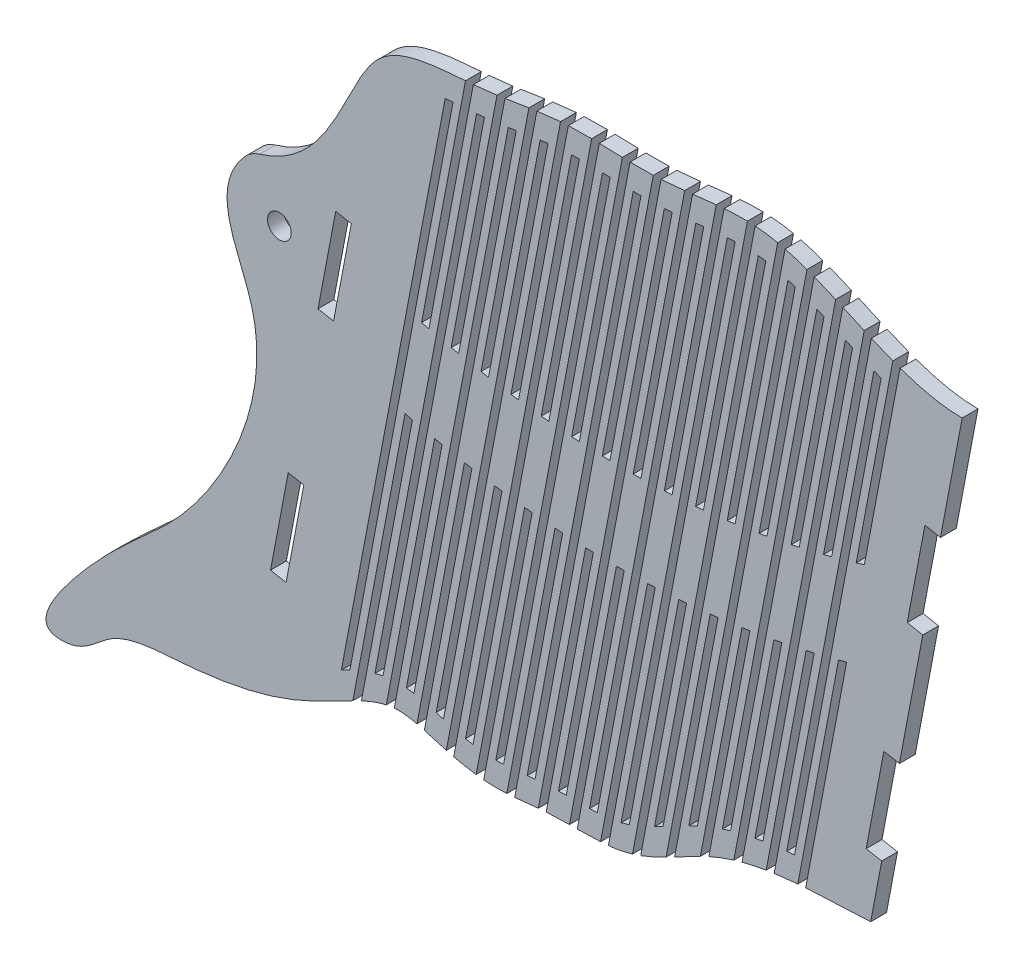
from build123d import *

# Parameters (mm, degrees)
SKETCH1_R           = 2.38125
BOSS_EXTRUDE1_DEPTH = 3.175
CUT_EXTRUDE1_DEPTH  = 3.175
CUT_EXTRUDE2_DEPTH  = 5.08


with BuildPart() as part:
    # Sketch1 → Boss-Extrude1 (new body)
    with BuildSketch(Plane.XY):
        with BuildLine():
            add(Edge.make_bspline(
                [(262.965914683, 222.176563319), (252.776182879, 221.634979572), (234.614709745, 222.046492101), (215.715433641, 207.839747079), (199.776901525, 209.397609599), (187.370815085, 207.163447991), (177.227729499, 209.313258014), (167.480873749, 212.716340292), (157.834954982, 208.138608283), (144.68413983, 200.908281223), (128.175962311, 197.807744291), (111.188740979, 197.561370772), (105.088410147, 189.875870369), (93.870335672, 189.645044346), (109.304742609, 211.179651417), (127.811684606, 222.332999181), (145.741997275, 257.387754377), (132.813268714, 279.641803985), (133.809830146, 288.366944204), (137.393134843, 292.39498657)],
                knots=[0, 0, 0, 0, 0.108342834, 0.179804744, 0.231480998, 0.269558306, 0.310047914, 0.3388763, 0.372965647, 0.414981364, 0.49670609, 0.548446486, 0.578686653, 0.5942621, 0.641812672, 0.740934207, 0.901270829, 0.951710023, 0.994791035, 0.994791035, 0.994791035, 0.994791035], degree=3))
            Line((262.965914683, 222.176563319), (265.179854829, 233.84009186))
            Line((265.179854829, 233.84009186), (262.060552767, 234.432189529))
            Line((262.060552767, 234.432189529), (265.61313878, 253.148001898))
            Line((265.61313878, 253.148001898), (268.732440842, 252.555904229))
            Line((268.732440842, 252.555904229), (273.419011411, 277.245799168))
            Line((273.419011411, 277.245799168), (270.299709349, 277.837896837))
            Line((270.299709349, 277.837896837), (273.852295362, 296.553709205))
            Line((273.852295362, 296.553709205), (276.971597424, 295.961611536))
            Line((276.971597424, 295.961611536), (281.327401418, 318.908954674))
            add(Edge.make_bspline(
                [(140.318014573, 294.258156132), (144.61023342, 295.541868895), (152.097280003, 300.900381836), (157.875345692, 312.565873253), (165.48589024, 327.616550709), (184.032411792, 327.009565774), (201.917650096, 331.22328454), (220.739688935, 328.976192412), (248.527948343, 335.404657274), (266.945821835, 318.91013876), (281.327401418, 318.908954674)],
                knots=[0.008505479, 0.008505479, 0.008505479, 0.008505479, 0.084335044, 0.182888737, 0.251299887, 0.38213826, 0.483340136, 0.605314817, 0.732969852, 1, 1, 1, 1], degree=3))
            ThreePointArc((140.318014573, 294.258156132), (138.725920408, 293.53010797), (137.393134843, 292.39498657))
        make_face()
        with Locations((144.299338724, 283.736845769)):
            Circle(SKETCH1_R, mode=Mode.SUBTRACT)
    extrude(amount=BOSS_EXTRUDE1_DEPTH)

    # Sketch2 → Cut-Extrude1 (cut)
    with BuildSketch(Plane.XY.offset(3.175)):
        with BuildLine():
            add(Edge.make_bspline(
                [(253.499129309, 281.265187804), (254.043605807, 281.405759721), (254.587907948, 281.549220511), (255.132035737, 281.695570177)],
                knots=[0.668787999, 0.668787999, 0.668787999, 0.668787999, 0.68090048, 0.68090048, 0.68090048, 0.68090048], degree=3))
            Line((255.132035737, 281.695570177), (265.175333522, 334.605894149))
            Line((265.175333522, 334.605894149), (263.624121137, 334.605894149))
            Line((263.624121137, 334.605894149), (253.499129309, 281.265187804))
        make_face()
        with BuildLine():
            Line((245.215002967, 204.934043958), (246.761298802, 204.908142481))
            Line((246.761298802, 204.908142481), (258.146846352, 264.889736415))
            add(Edge.make_bspline(
                [(256.510850204, 264.443076714), (257.056244674, 264.589276612), (257.601576721, 264.738163179), (258.146846352, 264.889736415)],
                knots=[0.805120326, 0.805120326, 0.805120326, 0.805120326, 0.818669259, 0.818669259, 0.818669259, 0.818669259], degree=3))
            Line((256.510850204, 264.443076714), (245.215002967, 204.934043958))
        make_face()
        with BuildLine():
            add(Edge.make_bspline(
                [(247.690951874, 226.150024326), (247.165611556, 226.104180829), (246.638974138, 226.054367703), (246.111253526, 225.999953943)],
                knots=[0.092913574, 0.092913574, 0.092913574, 0.092913574, 0.102289269, 0.102289269, 0.102289269, 0.102289269], degree=3))
            Line((247.690951874, 226.150024326), (265.064099585, 317.675626133))
            add(Edge.make_bspline(
                [(263.622438548, 318.252766971), (264.099576579, 318.057329111), (264.580064116, 317.864646955), (265.064099585, 317.675626133)],
                knots=[0.896580018, 0.896580018, 0.896580018, 0.896580018, 0.905747211, 0.905747211, 0.905747211, 0.905747211], degree=3))
            Line((263.622438548, 318.252766971), (246.111253526, 225.999953943))
        make_face()
        with BuildLine():
            Line((239.029819629, 205.037649869), (240.576115463, 205.011748391))
            Line((240.576115463, 205.011748391), (251.622197629, 263.204963265))
            add(Edge.make_bspline(
                [(249.999021721, 262.825843438), (250.540141691, 262.949576802), (251.081200325, 263.075950079), (251.622197629, 263.204963265)],
                knots=[0.751221614, 0.751221614, 0.751221614, 0.751221614, 0.764652129, 0.764652129, 0.764652129, 0.764652129], degree=3))
            Line((249.999021721, 262.825843438), (239.029819629, 205.037649869))
        make_face()
        with BuildLine():
            add(Edge.make_bspline(
                [(241.337825106, 225.36886694), (240.803093478, 225.280719583), (240.267885039, 225.185949449), (239.73251013, 225.083842468)],
                knots=[0.130418732, 0.130418732, 0.130418732, 0.130418732, 0.139836165, 0.139836165, 0.139836165, 0.139836165], degree=3))
            Line((241.337825106, 225.36886694), (259.320014432, 320.103035281))
            add(Edge.make_bspline(
                [(257.890031503, 320.741698985), (258.363755003, 320.529426446), (258.840381441, 320.316231273), (259.320014432, 320.103035281)],
                knots=[0.858867817, 0.858867817, 0.858867817, 0.858867817, 0.868457537, 0.868457537, 0.868457537, 0.868457537], degree=3))
            Line((257.890031503, 320.741698985), (239.73251013, 225.083842468))
        make_face()
        with BuildLine():
            Line((232.84463629, 205.141255779), (234.390932125, 205.115354302))
            Line((234.390932125, 205.115354302), (245.148329805, 261.787715172))
            add(Edge.make_bspline(
                [(243.537643759, 261.474394711), (244.074599393, 261.576240113), (244.61149474, 261.680680265), (245.148329805, 261.787715172)],
                knots=[0.697788906, 0.697788906, 0.697788906, 0.697788906, 0.711104053, 0.711104053, 0.711104053, 0.711104053], degree=3))
            Line((243.537643759, 261.474394711), (232.84463629, 205.141255779))
        make_face()
        with BuildLine():
            add(Edge.make_bspline(
                [(234.860021519, 223.930884371), (234.310062445, 223.772921472), (233.760927699, 223.604859066), (233.212957192, 223.425915044)],
                knots=[0.168429697, 0.168429697, 0.168429697, 0.168429697, 0.178137216, 0.178137216, 0.178137216, 0.178137216], degree=3))
            Line((234.860021519, 223.930884371), (253.598134874, 322.647428436))
            add(Edge.make_bspline(
                [(252.163030291, 323.259110131), (252.638612159, 323.0601036), (253.116939993, 322.855850634), (253.598134874, 322.647428436)],
                knots=[0.819270674, 0.819270674, 0.819270674, 0.819270674, 0.829371507, 0.829371507, 0.829371507, 0.829371507], degree=3))
            Line((252.163030291, 323.259110131), (233.212957192, 223.425915044))
        make_face()
        with BuildLine():
            Line((226.659452952, 205.24486169), (228.205748786, 205.218960212))
            Line((228.205748786, 205.218960212), (238.723942554, 260.631141732))
            add(Edge.make_bspline(
                [(237.125429941, 260.381953617), (237.65832675, 260.462465209), (238.191164286, 260.545527914), (238.723942554, 260.631141732)],
                knots=[0.644810319, 0.644810319, 0.644810319, 0.644810319, 0.658013022, 0.658013022, 0.658013022, 0.658013022], degree=3))
            Line((237.125429941, 260.381953617), (226.659452952, 205.24486169))
        make_face()
        with BuildLine():
            add(Edge.make_bspline(
                [(228.182680044, 221.44169188), (227.62915356, 221.18605526), (227.085464807, 220.9242222), (226.525650291, 220.646903869), (226.500774627, 220.634565098), (226.475917658, 220.622219916)],
                knots=[0.208362401, 0.208362401, 0.208362401, 0.208362401, 0.21875, 0.21875, 0.219233424, 0.219233424, 0.219233424, 0.219233424], degree=3))
            Line((228.182680044, 221.44169188), (247.826108711, 324.927638132))
            add(Edge.make_bspline(
                [(246.365298916, 325.403899059), (246.546035345, 325.348303874), (246.727206568, 325.29128004), (247.21336108, 325.134927326), (247.519123138, 325.033093448), (247.826108711, 324.927638132)],
                knots=[0.777218205, 0.777218205, 0.777218205, 0.777218205, 0.78125, 0.78125, 0.788010833, 0.788010833, 0.788010833, 0.788010833], degree=3))
            Line((246.365298916, 325.403899059), (226.475917658, 220.622219916))
        make_face()
        with BuildLine():
            Line((220.474269613, 205.3484676), (222.020565448, 205.322566123))
            Line((222.020565448, 205.322566123), (232.347790116, 259.728679999))
            add(Edge.make_bspline(
                [(230.761147646, 259.542026439), (231.290086761, 259.601735375), (231.818967582, 259.663953228), (232.347790116, 259.728679999)],
                knots=[0.592274468, 0.592274468, 0.592274468, 0.592274468, 0.605367529, 0.605367529, 0.605367529, 0.605367529], degree=3))
            Line((230.761147646, 259.542026439), (220.474269613, 205.3484676))
        make_face()
        with BuildLine():
            add(Edge.make_bspline(
                [(221.31044637, 217.925763985), (220.728454403, 217.619691582), (220.155323639, 217.322096361), (219.590497955, 217.036825093)],
                knots=[0.254448206, 0.254448206, 0.254448206, 0.254448206, 0.2669221, 0.2669221, 0.2669221, 0.2669221], degree=3))
            Line((221.31044637, 217.925763985), (241.914774696, 326.473943123))
            add(Edge.make_bspline(
                [(240.402355557, 326.678314558), (240.51553003, 326.666479541), (240.628655957, 326.653854383), (241.131333589, 326.594229306), (241.522161775, 326.538606176), (241.914774696, 326.473943123)],
                knots=[0.731724904, 0.731724904, 0.731724904, 0.731724904, 0.734375, 0.734375, 0.743474077, 0.743474077, 0.743474077, 0.743474077], degree=3))
            Line((240.402355557, 326.678314558), (219.590497955, 217.036825093))
        make_face()
        with BuildLine():
            Line((214.289086275, 205.452073511), (215.835382109, 205.426172033))
            Line((215.835382109, 205.426172033), (226.018678141, 259.074037877))
            add(Edge.make_bspline(
                [(224.443614913, 258.948386336), (224.968693332, 258.987802088), (225.493714406, 259.029685935), (226.018678141, 259.074037877)],
                knots=[0.540170436, 0.540170436, 0.540170436, 0.540170436, 0.553156541, 0.553156541, 0.553156541, 0.553156541], degree=3))
            Line((224.443614913, 258.948386336), (214.289086275, 205.452073511))
        make_face()
        with BuildLine():
            add(Edge.make_bspline(
                [(214.517894834, 214.829619296), (214.247034512, 214.737836871), (213.978102393, 214.652055286), (213.430222607, 214.489129562), (213.151410621, 214.41255175), (212.87434127, 214.343145452)],
                knots=[0.305963237, 0.305963237, 0.305963237, 0.305963237, 0.3125, 0.3125, 0.319373089, 0.319373089, 0.319373089, 0.319373089], degree=3))
            Line((214.517894834, 214.829619296), (235.769524156, 326.787923887))
            add(Edge.make_bspline(
                [(234.201393662, 326.698795529), (234.255346074, 326.702633485), (234.309221369, 326.706393879), (234.838026355, 326.742575126), (235.306922462, 326.768863442), (235.769524156, 326.787923887)],
                knots=[0.68638957, 0.68638957, 0.68638957, 0.68638957, 0.6875, 0.6875, 0.697304527, 0.697304527, 0.697304527, 0.697304527], degree=3))
            Line((234.201393662, 326.698795529), (212.87434127, 214.343145452))
        make_face()
        with BuildLine():
            Line((208.103902936, 205.555679421), (209.650198771, 205.529777944))
            Line((209.650198771, 205.529777944), (219.735460771, 258.66117873))
            add(Edge.make_bspline(
                [(218.171697576, 258.595058271), (218.693008399, 258.614669845), (219.214262795, 258.636709998), (219.735460771, 258.66117873)],
                knots=[0.488487746, 0.488487746, 0.488487746, 0.488487746, 0.501369475, 0.501369475, 0.501369475, 0.501369475], degree=3))
            Line((218.171697576, 258.595058271), (208.103902936, 205.555679421))
        make_face()
        with BuildLine():
            add(Edge.make_bspline(
                [(208.099228735, 213.703186156), (207.591075339, 213.677150944), (207.070084736, 213.658996658), (206.537198661, 213.646196164)],
                knots=[0.355873482, 0.355873482, 0.355873482, 0.355873482, 0.366464143, 0.366464143, 0.366464143, 0.366464143], degree=3))
            Line((208.099228735, 213.703186156), (229.459237081, 326.232455518))
            add(Edge.make_bspline(
                [(227.873079236, 326.048355071), (228.407151252, 326.110395372), (228.935918369, 326.172328006), (229.459237081, 326.232455518)],
                knots=[0.645046779, 0.645046779, 0.645046779, 0.645046779, 0.655063219, 0.655063219, 0.655063219, 0.655063219], degree=3))
            Line((227.873079236, 326.048355071), (206.537198661, 213.646196164))
        make_face()
        with BuildLine():
            Line((201.918719597, 205.659285332), (203.465015432, 205.633383854))
            Line((203.465015432, 205.633383854), (213.497037926, 258.484307093))
            add(Edge.make_bspline(
                [(211.944306596, 258.476304952), (212.461939242, 258.476582023), (212.979516349, 258.479249404), (213.497037926, 258.484307093)],
                knots=[0.437216339, 0.437216339, 0.437216339, 0.437216339, 0.449996168, 0.449996168, 0.449996168, 0.449996168], degree=3))
            Line((211.944306596, 258.476304952), (201.918719597, 205.659285332))
        make_face()
        with BuildLine():
            add(Edge.make_bspline(
                [(201.874915521, 213.600647189), (201.363066188, 213.594670858), (200.844012269, 213.585825202), (200.318218815, 213.571754568)],
                knots=[0.395679123, 0.395679123, 0.395679123, 0.395679123, 0.404839, 0.404839, 0.404839, 0.404839], degree=3))
            Line((201.874915521, 213.600647189), (223.124845816, 325.550000927))
            add(Edge.make_bspline(
                [(221.550966655, 325.43058731), (221.691385054, 325.439704151), (221.83151345, 325.449244992), (222.358044019, 325.486768882), (222.742590767, 325.517232456), (223.124845816, 325.550000927)],
                knots=[0.6069211, 0.6069211, 0.6069211, 0.6069211, 0.609375, 0.609375, 0.616168854, 0.616168854, 0.616168854, 0.616168854], degree=3))
            Line((221.550966655, 325.43058731), (200.318218815, 213.571754568))
        make_face()
        with BuildLine():
            Line((195.733536259, 205.762891242), (197.279832094, 205.736989765))
            Line((197.279832094, 205.736989765), (207.30235278, 258.537855371))
            add(Edge.make_bspline(
                [(205.76039559, 258.586613795), (206.274435994, 258.56800776), (206.788421723, 258.551754952), (207.30235278, 258.537855371)],
                knots=[0.38634655, 0.38634655, 0.38634655, 0.38634655, 0.39902686, 0.39902686, 0.39902686, 0.39902686], degree=3))
            Line((205.76039559, 258.586613795), (195.733536259, 205.762891242))
        make_face()
        with BuildLine():
            add(Edge.make_bspline(
                [(195.607404973, 213.270535071), (195.299596957, 213.240436159), (194.995208565, 213.209395051), (194.469358789, 213.154700208), (194.246387588, 213.131206822), (194.0253074, 213.107825036)],
                knots=[0.431979794, 0.431979794, 0.431979794, 0.431979794, 0.4375, 0.4375, 0.44162397, 0.44162397, 0.44162397, 0.44162397], degree=3))
            Line((195.607404973, 213.270535071), (216.869510709, 325.284031734))
            add(Edge.make_bspline(
                [(215.319998499, 325.292988632), (215.832966234, 325.286572831), (216.34950204, 325.283200043), (216.869510709, 325.284031734)],
                knots=[0.570205478, 0.570205478, 0.570205478, 0.570205478, 0.579503584, 0.579503584, 0.579503584, 0.579503584], degree=3))
            Line((215.319998499, 325.292988632), (194.0253074, 213.107825036))
        make_face()
        with BuildLine():
            Line((189.54835292, 205.866497153), (191.094648755, 205.840595675))
            Line((191.094648755, 205.840595675), (201.150389427, 258.816471546))
            add(Edge.make_bspline(
                [(199.618958535, 258.920684841), (200.129489337, 258.883629799), (200.639966301, 258.848892034), (201.150389427, 258.816471546)],
                knots=[0.335869086, 0.335869086, 0.335869086, 0.335869086, 0.348452167, 0.348452167, 0.348452167, 0.348452167], degree=3))
            Line((199.618958535, 258.920684841), (189.54835292, 205.866497153))
        make_face()
        with BuildLine():
            add(Edge.make_bspline(
                [(189.291976124, 212.687978697), (188.767798722, 212.66285431), (188.257803915, 212.650005382), (187.75246868, 212.652428897), (187.743251753, 212.652478424), (187.734035582, 212.652533268)],
                knots=[0.473119308, 0.473119308, 0.473119308, 0.473119308, 0.484375, 0.484375, 0.484584129, 0.484584129, 0.484584129, 0.484584129], degree=3))
            Line((189.291976124, 212.687978697), (210.687875088, 325.406327809))
            add(Edge.make_bspline(
                [(209.145203902, 325.451324741), (209.655008256, 325.437403387), (210.16927386, 325.42199771), (210.687875088, 325.406327809)],
                knots=[0.53175045, 0.53175045, 0.53175045, 0.53175045, 0.541589122, 0.541589122, 0.541589122, 0.541589122], degree=3))
            Line((209.145203902, 325.451324741), (187.734035582, 212.652533268))
        make_face()
        with BuildLine():
            Line((183.363169582, 205.970103063), (184.909465416, 205.944201586))
            Line((184.909465416, 205.944201586), (195.040170688, 259.315007622))
            add(Edge.make_bspline(
                [(193.519027608, 259.473419396), (194.026128329, 259.418333062), (194.533176022, 259.365529137), (195.040170688, 259.315007622)],
                knots=[0.285775008, 0.285775008, 0.285775008, 0.285775008, 0.298263062, 0.298263062, 0.298263062, 0.298263062], degree=3))
            Line((193.519027608, 259.473419396), (183.363169582, 205.970103063))
        make_face()
        with BuildLine():
            add(Edge.make_bspline(
                [(183.160233801, 213.073123752), (182.665527017, 213.156792009), (182.166440011, 213.251825484), (181.662968815, 213.357330632)],
                knots=[0.518388217, 0.518388217, 0.518388217, 0.518388217, 0.529054659, 0.529054659, 0.529054659, 0.529054659], degree=3))
            Line((183.160233801, 213.073123752), (204.501914949, 325.505841361))
            add(Edge.make_bspline(
                [(202.943663498, 325.468757997), (203.408948923, 325.485851823), (203.879232757, 325.49727966), (204.403519658, 325.504619199), (204.452691314, 325.505255418), (204.501914949, 325.505841361)],
                knots=[0.49024737, 0.49024737, 0.49024737, 0.49024737, 0.5, 0.5, 0.501008159, 0.501008159, 0.501008159, 0.501008159], degree=3))
            Line((202.943663498, 325.468757997), (181.662968815, 213.357330632))
        make_face()
        with BuildLine():
            Line((177.177986243, 206.073708974), (178.724282078, 206.047807496))
            Line((178.724282078, 206.047807496), (188.970756077, 260.028508907))
            add(Edge.make_bspline(
                [(187.459671194, 260.239909503), (187.963418398, 260.167194062), (188.467113357, 260.096727198), (188.970756077, 260.028508907)],
                knots=[0.236055711, 0.236055711, 0.236055711, 0.236055711, 0.248450858, 0.248450858, 0.248450858, 0.248450858], degree=3))
            Line((187.459671194, 260.239909503), (177.177986243, 206.073708974))
        make_face()
        with BuildLine():
            add(Edge.make_bspline(
                [(177.225076757, 214.493923726), (177.082087581, 214.536102064), (176.937643096, 214.579039646), (176.455592769, 214.723027988), (176.111043281, 214.826996191), (175.757056886, 214.932200369)],
                knots=[0.559640224, 0.559640224, 0.559640224, 0.559640224, 0.5625, 0.5625, 0.569036403, 0.569036403, 0.569036403, 0.569036403], degree=3))
            Line((177.225076757, 214.493923726), (198.214631419, 325.07156078))
            add(Edge.make_bspline(
                [(196.622337665, 324.855134999), (197.158879608, 324.932589818), (197.689378664, 325.005222617), (198.214631419, 325.07156078)],
                knots=[0.445938647, 0.445938647, 0.445938647, 0.445938647, 0.456853695, 0.456853695, 0.456853695, 0.456853695], degree=3))
            Line((196.622337665, 324.855134999), (175.757056886, 214.932200369))
        make_face()
        with BuildLine():
            Line((170.992802905, 206.177314884), (172.539098739, 206.151413407))
            Line((172.539098739, 206.151413407), (182.941239899, 260.952204006))
            add(Edge.make_bspline(
                [(181.439992017, 261.215428105), (181.940459458, 261.125471009), (182.440875416, 261.037729643), (182.941239899, 260.952204006)],
                knots=[0.186702906, 0.186702906, 0.186702906, 0.186702906, 0.199007191, 0.199007191, 0.199007191, 0.199007191], degree=3))
            Line((181.439992017, 261.215428105), (170.992802905, 206.177314884))
        make_face()
        with BuildLine():
            add(Edge.make_bspline(
                [(171.311544497, 216.02864787), (170.822209481, 216.110835437), (170.31747786, 216.179213865), (169.797881894, 216.226468458)],
                knots=[0.593774444, 0.593774444, 0.593774444, 0.593774444, 0.601178236, 0.601178236, 0.601178236, 0.601178236], degree=3))
            Line((171.311544497, 216.02864787), (191.826394592, 324.105435803))
            add(Edge.make_bspline(
                [(190.227987237, 323.856802213), (190.317407744, 323.870363169), (190.406633097, 323.883966126), (190.944055391, 323.966289037), (191.387536745, 324.035830444), (191.826394592, 324.105435803)],
                knots=[0.404601926, 0.404601926, 0.404601926, 0.404601926, 0.40625, 0.40625, 0.414550148, 0.414550148, 0.414550148, 0.414550148], degree=3))
            Line((190.227987237, 323.856802213), (169.797881894, 216.226468458))
        make_face()
        with BuildLine():
            Line((164.807619566, 206.280920795), (166.353915401, 206.255019317))
            Line((166.353915401, 206.255019317), (176.950749479, 262.081495464))
            add(Edge.make_bspline(
                [(175.45912539, 262.395419844), (175.956384159, 262.288594554), (176.453592186, 262.183953095), (176.950749479, 262.081495464)],
                knots=[0.137708607, 0.137708607, 0.137708607, 0.137708607, 0.149923998, 0.149923998, 0.149923998, 0.149923998], degree=3))
            Line((175.45912539, 262.395419844), (164.807619566, 206.280920795))
        make_face()
        with BuildLine():
            add(Edge.make_bspline(
                [(165.098530412, 215.985635222), (164.951692639, 215.957281405), (164.805918041, 215.927302135), (164.257275806, 215.807958566), (163.86170494, 215.708551852), (163.474083699, 215.599820512)],
                knots=[0.622872753, 0.622872753, 0.622872753, 0.622872753, 0.625, 0.625, 0.630938134, 0.630938134, 0.630938134, 0.630938134], degree=3))
            Line((165.098530412, 215.985635222), (185.455827097, 323.232396792))
            add(Edge.make_bspline(
                [(183.876013404, 323.081718745), (184.318613327, 323.120573785), (184.763739433, 323.162023427), (185.292420493, 323.215480498), (185.374139375, 323.22387559), (185.455827097, 323.232396792)],
                knots=[0.367353748, 0.367353748, 0.367353748, 0.367353748, 0.375, 0.375, 0.376397743, 0.376397743, 0.376397743, 0.376397743], degree=3))
            Line((183.876013404, 323.081718745), (163.474083699, 215.599820512))
        make_face()
        with BuildLine():
            Line((158.622436228, 206.384526705), (160.168732062, 206.358625228))
            Line((160.168732062, 206.358625228), (170.998443496, 263.411951021))
            add(Edge.make_bspline(
                [(169.516237585, 263.775492455), (170.010356241, 263.652159141), (170.504424876, 263.530978664), (170.998443496, 263.411951021)],
                knots=[0.089065112, 0.089065112, 0.089065112, 0.089065112, 0.101193509, 0.101193509, 0.101193509, 0.101193509], degree=3))
            Line((169.516237585, 263.775492455), (158.622436228, 206.384526705))
        make_face()
        with BuildLine():
            add(Edge.make_bspline(
                [(158.448625133, 213.64098271), (157.858399151, 213.359970241), (157.288795255, 213.076407855), (156.737391, 212.797952585)],
                knots=[0.659099455, 0.659099455, 0.659099455, 0.659099455, 0.669986505, 0.669986505, 0.669986505, 0.669986505], degree=3))
            Line((158.448625133, 213.64098271), (179.150471098, 322.702906432))
            add(Edge.make_bspline(
                [(177.571664806, 322.557535597), (178.087914095, 322.609592403), (178.614868823, 322.657461264), (179.150471098, 322.702906432)],
                knots=[0.329493757, 0.329493757, 0.329493757, 0.329493757, 0.339364456, 0.339364456, 0.339364456, 0.339364456], degree=3))
            Line((177.571664806, 322.557535597), (156.737391, 212.797952585))
        make_face()
        with BuildLine():
            Line((184.512289521, 334.605894149), (182.961077136, 334.605894149))
            Line((182.961077136, 334.605894149), (172.833468021, 281.251399355))
            add(Edge.make_bspline(
                [(172.833468021, 281.251399355), (173.327643847, 281.127833748), (173.821684593, 281.006506324), (174.315590253, 280.887417083)],
                knots=[0.079793969, 0.079793969, 0.079793969, 0.079793969, 0.090455426, 0.090455426, 0.090455426, 0.090455426], degree=3))
            Line((174.315590253, 280.887417083), (184.512289521, 334.605894149))
        make_face()
        with BuildLine():
            add(Edge.make_bspline(
                [(260.052075242, 283.099036944), (260.601327279, 283.264680365), (261.15040097, 283.433278744), (261.699296322, 283.60483208)],
                knots=[0.71744309, 0.71744309, 0.71744309, 0.71744309, 0.729693323, 0.729693323, 0.729693323, 0.729693323], degree=3))
            Line((261.699296322, 283.60483208), (271.380183065, 334.605894177))
            Line((271.380183065, 334.605894177), (269.828970681, 334.605894177))
            Line((269.828970681, 334.605894177), (260.052075242, 283.099036944))
        make_face()
        with BuildLine():
            add(Edge.make_bspline(
                [(247.002253001, 279.726725908), (247.542111564, 279.843052805), (248.081799587, 279.962205385), (248.621317069, 280.084183648)],
                knots=[0.620672477, 0.620672477, 0.620672477, 0.620672477, 0.63265175, 0.63265175, 0.63265175, 0.63265175], degree=3))
            Line((248.621317069, 280.084183648), (258.970483983, 334.605894149))
            Line((258.970483983, 334.605894149), (257.419271598, 334.605894149))
            Line((257.419271598, 334.605894149), (247.002253001, 279.726725908))
        make_face()
        with BuildLine():
            add(Edge.make_bspline(
                [(240.55962131, 278.474036698), (241.095011062, 278.566900619), (241.63023392, 278.66252974), (242.165289894, 278.760924054)],
                knots=[0.57307896, 0.57307896, 0.57307896, 0.57307896, 0.584929326, 0.584929326, 0.584929326, 0.584929326], degree=3))
            Line((242.165289894, 278.760924054), (252.765634444, 334.605894149))
            Line((252.765634444, 334.605894149), (251.21442206, 334.605894149))
            Line((251.21442206, 334.605894149), (240.55962131, 278.474036698))
        make_face()
        with BuildLine():
            add(Edge.make_bspline(
                [(234.16950613, 277.49801614), (234.700568334, 277.568157963), (235.231467146, 277.641007031), (235.762202567, 277.716563345)],
                knots=[0.525990819, 0.525990819, 0.525990819, 0.525990819, 0.537716352, 0.537716352, 0.537716352, 0.537716352], degree=3))
            Line((235.762202567, 277.716563345), (246.560784906, 334.605894149))
            Line((246.560784906, 334.605894149), (245.009572521, 334.605894149))
            Line((245.009572521, 334.605894149), (234.16950613, 277.49801614))
        make_face()
        with BuildLine():
            add(Edge.make_bspline(
                [(227.830269208, 276.790033549), (228.357137844, 276.838155959), (228.88384644, 276.888930042), (229.410394999, 276.942355799)],
                knots=[0.479392289, 0.479392289, 0.479392289, 0.479392289, 0.490996852, 0.490996852, 0.490996852, 0.490996852], degree=3))
            Line((229.410394999, 276.942355799), (240.355935367, 334.605894149))
            Line((240.355935367, 334.605894149), (238.804722983, 334.605894149))
            Line((238.804722983, 334.605894149), (227.830269208, 276.790033549))
        make_face()
        with BuildLine():
            add(Edge.make_bspline(
                [(221.540355737, 276.341897856), (222.063158007, 276.368668045), (222.585803458, 276.398036572), (223.10829209, 276.430003436)],
                knots=[0.433268408, 0.433268408, 0.433268408, 0.433268408, 0.444755669, 0.444755669, 0.444755669, 0.444755669], degree=3))
            Line((223.10829209, 276.430003436), (234.151085829, 334.605894149))
            Line((234.151085829, 334.605894149), (232.599873444, 334.605894149))
            Line((232.599873444, 334.605894149), (221.540355737, 276.341897856))
        make_face()
        with BuildLine():
            add(Edge.make_bspline(
                [(215.298288522, 276.14582687), (215.817145327, 276.151878999), (216.335848408, 276.160478232), (216.854397758, 276.171624569)],
                knots=[0.38760496, 0.38760496, 0.38760496, 0.38760496, 0.398978407, 0.398978407, 0.398978407, 0.398978407], degree=3))
            Line((216.854397758, 276.171624569), (227.94623629, 334.605894149))
            Line((227.94623629, 334.605894149), (226.395023906, 334.605894149))
            Line((226.395023906, 334.605894149), (215.298288522, 276.14582687))
        make_face()
        with BuildLine():
            add(Edge.make_bspline(
                [(209.102662663, 276.19441926), (209.617689032, 276.180356703), (210.132564642, 276.168791999), (210.647289503, 276.159725146)],
                knots=[0.342388425, 0.342388425, 0.342388425, 0.342388425, 0.353651375, 0.353651375, 0.353651375, 0.353651375], degree=3))
            Line((210.647289503, 276.159725146), (221.741386752, 334.605894149))
            Line((221.741386752, 334.605894149), (220.190174367, 334.605894149))
            Line((220.190174367, 334.605894149), (209.102662663, 276.19441926))
        make_face()
        with BuildLine():
            add(Edge.make_bspline(
                [(202.952140695, 276.480628973), (203.463446169, 276.447026368), (203.974603748, 276.415874233), (204.485613432, 276.387172567)],
                knots=[0.297605934, 0.297605934, 0.297605934, 0.297605934, 0.308761546, 0.308761546, 0.308761546, 0.308761546], degree=3))
            Line((204.485613432, 276.387172567), (215.536537213, 334.605894149))
            Line((215.536537213, 334.605894149), (213.985324829, 334.605894149))
            Line((213.985324829, 334.605894149), (202.952140695, 276.480628973))
        make_face()
        with BuildLine():
            add(Edge.make_bspline(
                [(196.845448144, 276.997741788), (197.353137143, 276.945146922), (197.860681004, 276.894956906), (198.368079721, 276.847171741)],
                knots=[0.253245221, 0.253245221, 0.253245221, 0.253245221, 0.264296506, 0.264296506, 0.264296506, 0.264296506], degree=3))
            Line((198.368079721, 276.847171741), (209.331687675, 334.605894149))
            Line((209.331687675, 334.605894149), (207.78047529, 334.605894149))
            Line((207.78047529, 334.605894149), (196.845448144, 276.997741788))
        make_face()
        with BuildLine():
            add(Edge.make_bspline(
                [(190.781369447, 277.739353857), (191.285541602, 277.668289386), (191.789571264, 277.599585815), (192.293458441, 277.533243142)],
                knots=[0.209294588, 0.209294588, 0.209294588, 0.209294588, 0.220244421, 0.220244421, 0.220244421, 0.220244421], degree=3))
            Line((192.293458441, 277.533243142), (203.126838136, 334.605894149))
            Line((203.126838136, 334.605894149), (201.575625752, 334.605894149))
            Line((201.575625752, 334.605894149), (190.781369447, 277.739353857))
        make_face()
        with BuildLine():
            add(Edge.make_bspline(
                [(184.758744213, 278.699351974), (185.259494654, 278.610317012), (185.760105165, 278.523600574), (186.260575743, 278.439202661)],
                knots=[0.16574287, 0.16574287, 0.16574287, 0.16574287, 0.176593993, 0.176593993, 0.176593993, 0.176593993], degree=3))
            Line((186.260575743, 278.439202661), (196.921988598, 334.605894149))
            Line((196.921988598, 334.605894149), (195.370776213, 334.605894149))
            Line((195.370776213, 334.605894149), (184.758744213, 278.699351974))
        make_face()
        with BuildLine():
            add(Edge.make_bspline(
                [(178.776463775, 279.871895441), (179.273883427, 279.765367013), (179.771165612, 279.661116231), (180.268310336, 279.559143095)],
                knots=[0.122579398, 0.122579398, 0.122579398, 0.122579398, 0.133334434, 0.133334434, 0.133334434, 0.133334434], degree=3))
            Line((180.268310336, 279.559143095), (190.717139059, 334.605894149))
            Line((190.717139059, 334.605894149), (189.165926675, 334.605894149))
            Line((189.165926675, 334.605894149), (178.776463775, 279.871895441))
        make_face()
    extrude(amount=-CUT_EXTRUDE1_DEPTH, mode=Mode.SUBTRACT)

    # Sketch3 → Cut-Extrude2 (cut)
    with BuildSketch(Plane.XY.offset(3.175)):
        Polygon((142.528456034, 223.068496098), (145.647758096, 222.476398429), (149.200344109, 241.192210798), (146.081042047, 241.784308467), align=None)
        Polygon((152.056278926, 273.263183821), (155.175580988, 272.671086152), (158.728167001, 291.386898521), (155.608864939, 291.97899619), align=None)
    extrude(amount=-CUT_EXTRUDE2_DEPTH, mode=Mode.SUBTRACT)


solid = part.part
